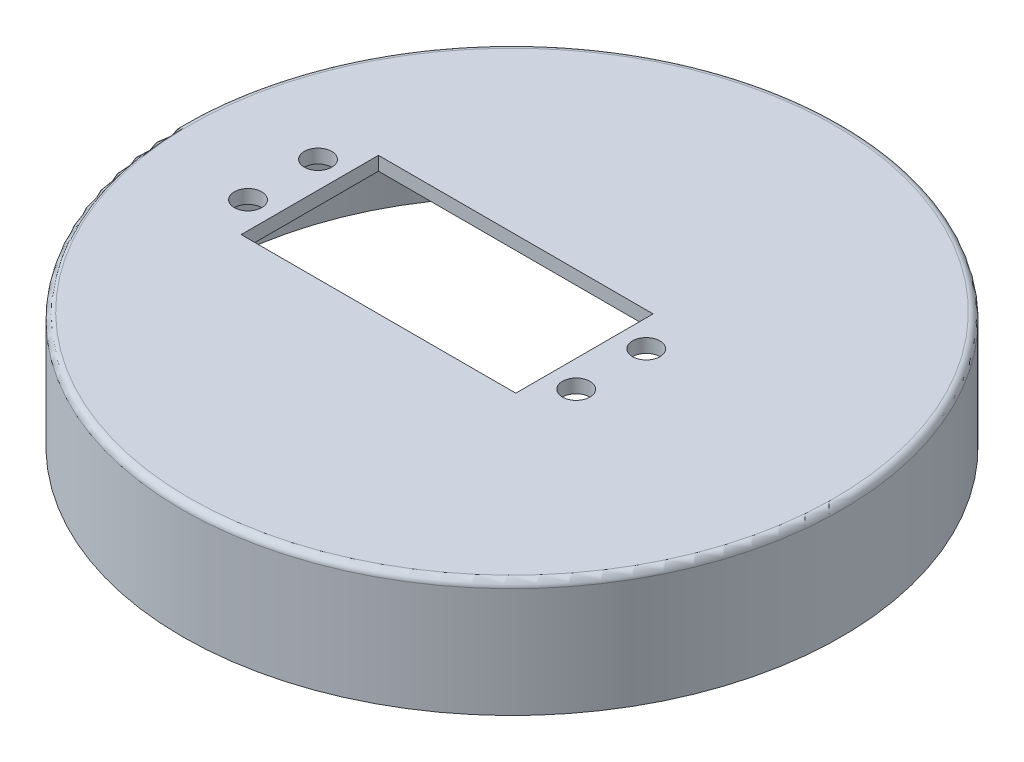
from build123d import *

# Parameters (mm, degrees)
SKETCH1_R           = 48
SKETCH1_R_2         = 44.5
BOSS_EXTRUDE3_DEPTH = 15
BOSS_EXTRUDE4_START = 2
SKETCH1_5_R         = 48
BOSS_EXTRUDE4_DEPTH = 2
FILLET1_R           = 1
CUT_EXTRUDE1_DEPTH  = 30
SKETCH4_R           = 2
CUT_EXTRUDE2_DEPTH  = 10


with BuildPart() as part:
    # Sketch1 → Boss-Extrude3 (new body)
    with BuildSketch(Plane(origin=(0, 0, 0), x_dir=(1, 0, 0), z_dir=(0, 1, 0))):
        Circle(SKETCH1_R)
        Circle(SKETCH1_R_2, mode=Mode.SUBTRACT)
    extrude(amount=-BOSS_EXTRUDE3_DEPTH)

    # Sketch1_5 → Boss-Extrude4 (add)
    with BuildSketch(Plane(origin=(0, 0, 0), x_dir=(1, 0, 0), z_dir=(0, 1, 0)).offset(BOSS_EXTRUDE4_START)):
        Circle(SKETCH1_5_R)
    extrude(amount=-BOSS_EXTRUDE4_DEPTH)

    # Fillet1
    fillet1_edges = [part.edges().sort_by_distance(p)[0] for p in [
        (-44.5, 0, 0),
        (-48, 2, 0),
    ]]
    fillet(fillet1_edges, radius=FILLET1_R)

    # Sketch3 → Cut-Extrude1 (cut)
    with BuildSketch(Plane(origin=(0, 2, 0), x_dir=(1, 0, 0), z_dir=(0, 1, 0))):
        Polygon((-29.45, 10), (-29.45, 0), (-29.45, -10), (10.55, -10), (10.55, 10), align=None)
    extrude(amount=-CUT_EXTRUDE1_DEPTH, mode=Mode.SUBTRACT)

    # Sketch4 → Cut-Extrude2 (cut)
    with BuildSketch(Plane(origin=(0, 2, 0), x_dir=(1, 0, 0), z_dir=(0, 1, 0))):
        with Locations((-33.34886579, -5.09860841)):
            Circle(SKETCH4_R)
        with Locations((14.44886579, -5.09860841)):
            Circle(SKETCH4_R)
        with Locations((14.44886579, 5.09860841)):
            Circle(SKETCH4_R)
        with Locations((-33.34886579, 5.09860841)):
            Circle(SKETCH4_R)
    extrude(amount=-CUT_EXTRUDE2_DEPTH, mode=Mode.SUBTRACT)


solid = part.part
